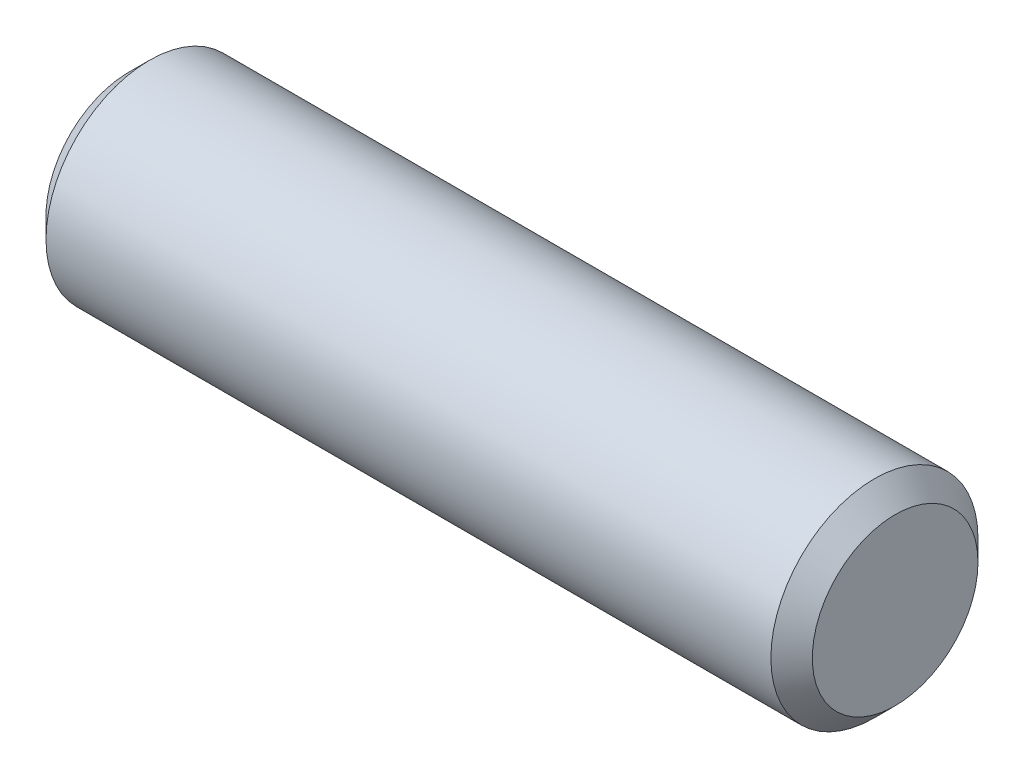
from build123d import *

# Parameters (mm, degrees)
SKETCH1_R           = 10
BOSS_EXTRUDE1_DEPTH = 74
CHAMFER1_SIZE       = 2


with BuildPart() as part:
    # Sketch1 → Boss-Extrude1 (new body)
    with BuildSketch(Plane(origin=(0, 0, 0), x_dir=(0, 0, -1), z_dir=(1, 0, 0))):
        Circle(SKETCH1_R)
    extrude(amount=BOSS_EXTRUDE1_DEPTH)

    # Chamfer1
    chamfer1_edges = [part.edges().sort_by_distance(p)[0] for p in [
        (0, 0, 10),
        (74, 0, 10),
    ]]
    chamfer(chamfer1_edges, length=CHAMFER1_SIZE)


solid = part.part
